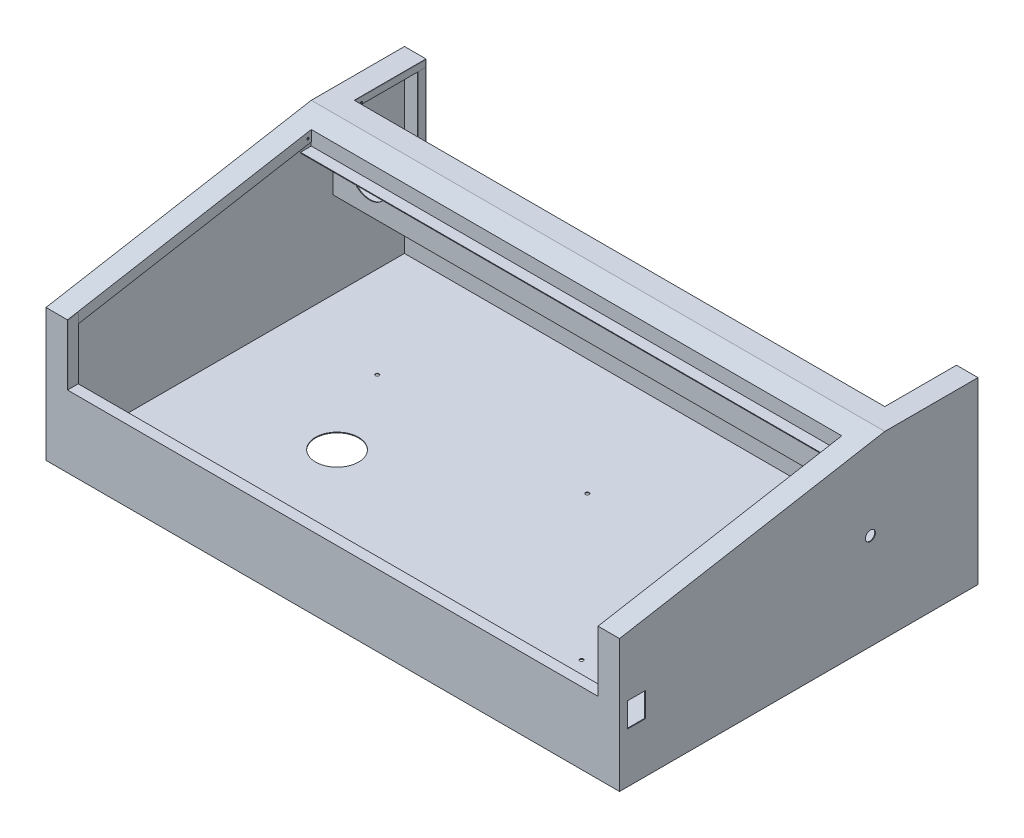
from build123d import *

# Parameters (mm, degrees)
CROQUIS1_W               = 800
CROQUIS1_H               = 500
SALIENTE_EXTRUIR1_DEPTH  = 1
SALIENTE_EXTRUIR2_DEPTH  = 1
SALIENTE_EXTRUIR3_DEPTH  = 1
CROQUIS5_W               = 800
CROQUIS5_H               = 250
SALIENTE_EXTRUIR4_DEPTH  = 1
CROQUIS6_W               = 800
CROQUIS6_H               = 184.759017138
SALIENTE_EXTRUIR5_DEPTH  = 1
SALIENTE_EXTRUIR8_DEPTH  = 800
CROQUIS8_W               = 740
CROQUIS8_H               = 340
CORTAR_EXTRUIR3_DEPTH    = 150
CROQUIS13_W              = 740
CROQUIS13_H              = 15
SALIENTE_EXTRUIR10_DEPTH = 1
SALIENTE_EXTRUIR21_DEPTH = 1
SALIENTE_EXTRUIR23_DEPTH = 1
SALIENTE_EXTRUIR25_DEPTH = 1
SALIENTE_EXTRUIR31_DEPTH = 1
SALIENTE_EXTRUIR32_DEPTH = 1
CROQUIS21_W              = 740
CROQUIS21_H              = 15
SALIENTE_EXTRUIR35_DEPTH = 1
CROQUIS22_W              = 740
CROQUIS22_H              = 100
CORTAR_EXTRUIR4_DEPTH    = 100
CROQUIS23_W              = 798
CROQUIS23_H              = 127
SALIENTE_EXTRUIR36_DEPTH = 1
CROQUIS24_W              = 798
CROQUIS24_H              = 1
SALIENTE_EXTRUIR40_DEPTH = 99
CROQUIS25_W              = 740
CROQUIS25_H              = 1
SALIENTE_EXTRUIR41_DEPTH = 10
CROQUIS26_W              = 99
CROQUIS26_H              = 9
SALIENTE_EXTRUIR43_DEPTH = 1
CROQUIS27_W              = 99
CROQUIS27_H              = 9
SALIENTE_EXTRUIR45_DEPTH = 1
CROQUIS28_W              = 10
CROQUIS28_H              = 90
SALIENTE_EXTRUIR47_DEPTH = 1
CROQUIS29_W              = 740
CROQUIS29_H              = 10
SALIENTE_EXTRUIR48_DEPTH = 1
CROQUIS30_W              = 10
CROQUIS30_H              = 90
SALIENTE_EXTRUIR49_DEPTH = 1
CROQUIS31_R              = 6
CROQUIS31_W              = 180
CROQUIS31_H              = 50
CROQUIS31_W_2            = 35
CROQUIS31_H_2            = 37
CORTAR_EXTRUIR5_DEPTH    = 1
CROQUIS35_W              = 25
CROQUIS35_H              = 34
CORTAR_EXTRUIR8_DEPTH    = 1
CROQUIS36_R              = 7
CORTAR_EXTRUIR9_DEPTH    = 1
CROQUIS37_R              = 30
CROQUIS37_R_2            = 2.5
CROQUIS37_R_3            = 8.5
CORTAR_EXTRUIR11_DEPTH   = 1
CROQUIS40_R              = 1.5
CORTAR_EXTRUIR12_DEPTH   = 1
CROQUIS41_R              = 1.5
CORTAR_EXTRUIR13_DEPTH   = 1
CROQUIS42_R              = 24.75
CORTAR_EXTRUIR14_DEPTH   = 1


with BuildPart() as part:
    # Croquis1 → Saliente-Extruir1 (new body)
    with BuildSketch(Plane(origin=(0, 0, 0), x_dir=(1, 0, 0), z_dir=(0, 1, 0))):
        Rectangle(CROQUIS1_W, CROQUIS1_H)
    extrude(amount=SALIENTE_EXTRUIR1_DEPTH)

    # Croquis3 → Saliente-Extruir2 (add)
    with BuildSketch(Plane(origin=(400, 0, 0), x_dir=(0, 0, -1), z_dir=(1, 0, 0))):
        Polygon((-250, 0), (250, 0), (250, 250), (120, 250), (-250, 184.759017138), align=None)
    extrude(amount=-SALIENTE_EXTRUIR2_DEPTH)

    # Croquis4 → Saliente-Extruir3 (add)
    with BuildSketch(Plane.ZY.offset(400)):
        Polygon((-250, 250), (-250, 1), (250, 1), (250, 184.759017138), (-120, 250), align=None)
    extrude(amount=-SALIENTE_EXTRUIR3_DEPTH)

    # Croquis5 → Saliente-Extruir4 (add)
    with BuildSketch(Plane(origin=(0, 0, -250), x_dir=(-1, 0, 0), z_dir=(0, 0, -1))):
        with Locations((0, 125)):
            Rectangle(CROQUIS5_W, CROQUIS5_H)
    extrude(amount=-SALIENTE_EXTRUIR4_DEPTH)

    # Croquis6 → Saliente-Extruir5 (add)
    with BuildSketch(Plane.XY.offset(250)):
        with Locations((0, 92.379508569)):
            Rectangle(CROQUIS6_W, CROQUIS6_H)
    extrude(amount=-SALIENTE_EXTRUIR5_DEPTH)

    # Croquis7 → Saliente-Extruir8 (add)
    with BuildSketch(Plane(origin=(400, 0, 0), x_dir=(0, 0, -1), z_dir=(1, 0, 0))):
        Polygon((250, 250), (250, 249), (120, 249), (-250, 183.759017138), (-250, 184.759017138), (120, 250), align=None)
    extrude(amount=-SALIENTE_EXTRUIR8_DEPTH)

    # Croquis8 → Cortar-Extruir3 (cut)
    with BuildSketch(Plane(origin=(0, 250, -272.39856565), x_dir=(1, 0, 0), z_dir=(0, -1, 0))):
        with Locations((0, 352.39856565)):
            Rectangle(CROQUIS8_W, CROQUIS8_H)
    extrude(amount=CORTAR_EXTRUIR3_DEPTH, mode=Mode.SUBTRACT)

    # Croquis13 → Saliente-Extruir10 (add)
    with BuildSketch(Plane(origin=(0, 100, 0), x_dir=(1, 0, 0), z_dir=(0, 1, 0))):
        with Locations((0, -242.5)):
            Rectangle(CROQUIS13_W, CROQUIS13_H)
    extrude(amount=-SALIENTE_EXTRUIR10_DEPTH)

    # Croquis16 → Saliente-Extruir25 (add)
    with BuildSketch(Plane.ZY.offset(-370)):
        Polygon((-90, 244.710190579), (-92.644904711, 229.710190579), (235, 171.937553787), (235, 187.403921848), align=None)
    extrude(amount=-SALIENTE_EXTRUIR25_DEPTH)

    # Croquis18 → Saliente-Extruir31 (add)
    with BuildSketch(Plane.XY.offset(-90)):
        Polygon((370, 244.710190579), (370, 224.710190579), (-370.133807939, 224.710190579), (-370, 244.710190579), align=None)
    extrude(amount=-SALIENTE_EXTRUIR31_DEPTH)

    # Croquis19 → Saliente-Extruir32 (add)
    with BuildSketch(Plane(origin=(-370, 0, 0), x_dir=(0, 0, -1), z_dir=(1, 0, 0))):
        Polygon((90, 244.710190579), (90, 229.710190579), (-235, 172.403921848), (-235, 187.403921848), align=None)
    extrude(amount=-SALIENTE_EXTRUIR32_DEPTH)

    # Croquis22 → Cortar-Extruir4 (cut)
    with BuildSketch(Plane(origin=(0, 250, 0), x_dir=(1, 0, 0), z_dir=(0, 1, 0))):
        with Locations((0, 200)):
            Rectangle(CROQUIS22_W, CROQUIS22_H)
    extrude(amount=-CORTAR_EXTRUIR4_DEPTH, mode=Mode.SUBTRACT)

    # Croquis23 → Saliente-Extruir36 (add)
    with BuildSketch(Plane(origin=(0, 0, -150), x_dir=(-1, 0, 0), z_dir=(0, 0, -1))):
        with Locations((0, 185.5)):
            Rectangle(CROQUIS23_W, CROQUIS23_H)
    extrude(amount=-SALIENTE_EXTRUIR36_DEPTH)

    # Croquis25 → Saliente-Extruir41 (add)
    with BuildSketch(Plane(origin=(0, 0, -150), x_dir=(-1, 0, 0), z_dir=(0, 0, -1))):
        with Locations((0, 239.5)):
            Rectangle(CROQUIS25_W, CROQUIS25_H)
    extrude(amount=SALIENTE_EXTRUIR41_DEPTH)

    # Croquis31 → Cortar-Extruir5 (cut)
    with BuildSketch(Plane(origin=(0, 0, -250), x_dir=(-1, 0, 0), z_dir=(0, 0, -1))):
        with Locations((-79, 91)):
            Circle(CROQUIS31_R)
        with Locations((-90, 30)):
            Circle(CROQUIS31_R)
        with Locations((-30, 30)):
            Circle(CROQUIS31_R)
        with Locations((300, 85)):
            Circle(CROQUIS31_R)
        with Locations((140, 70)):
            Rectangle(CROQUIS31_W, CROQUIS31_H)
        Polygon((-350, 52), (-338, 52), (-328, 42), (-328, 20), (-360, 20), (-360, 42), align=None)
        with Locations((-292.5, 51.5)):
            Rectangle(CROQUIS31_W_2, CROQUIS31_H_2)
        with Locations((-233.5, 51.5)):
            Rectangle(CROQUIS31_W_2, CROQUIS31_H_2)
    extrude(amount=-CORTAR_EXTRUIR5_DEPTH, mode=Mode.SUBTRACT)

    # Croquis35 → Cortar-Extruir8 (cut)
    with BuildSketch(Plane(origin=(400, 0, 0), x_dir=(0, 0, -1), z_dir=(1, 0, 0))):
        with Locations((-226.5, 87)):
            Rectangle(CROQUIS35_W, CROQUIS35_H)
    extrude(amount=-CORTAR_EXTRUIR8_DEPTH, mode=Mode.SUBTRACT)

    # Croquis36 → Cortar-Extruir9 (cut)
    with BuildSketch(Plane(origin=(400, 0, 0), x_dir=(0, 0, -1), z_dir=(1, 0, 0))):
        with Locations((100, 134)):
            Circle(CROQUIS36_R)
    extrude(amount=-CORTAR_EXTRUIR9_DEPTH, mode=Mode.SUBTRACT)

    # Croquis37 → Cortar-Extruir11 (cut)
    with BuildSketch(Plane(origin=(0, 1, 0), x_dir=(1, 0, 0), z_dir=(0, 1, 0))):
        with Locations((-209, -35)):
            Circle(CROQUIS37_R)
        with Locations((261, 3)):
            Circle(CROQUIS37_R)
        with Locations((325.5, -118.5)):
            Circle(CROQUIS37_R_2)
        with Locations((325.5, 39.5)):
            Circle(CROQUIS37_R_2)
        with Locations((215.5, 39.5)):
            Circle(CROQUIS37_R_2)
        with Locations((215.5, -118.5)):
            Circle(CROQUIS37_R_2)
        with Locations((18.5, -164.5)):
            Circle(CROQUIS37_R_2)
        with Locations((-106.5, -164.5)):
            Circle(CROQUIS37_R_2)
        with Locations((-271.5, -164.5)):
            Circle(CROQUIS37_R_2)
        with Locations((18.5, 86.5)):
            Circle(CROQUIS37_R_2)
        with Locations((-271.5, 83.5)):
            Circle(CROQUIS37_R_2)
        with Locations((195, -214)):
            Circle(CROQUIS37_R_3)
        with Locations((320, -214)):
            Circle(CROQUIS37_R_3)
    extrude(amount=-CORTAR_EXTRUIR11_DEPTH, mode=Mode.SUBTRACT)

    # Croquis40 → Cortar-Extruir12 (cut)
    with BuildSketch(Plane(origin=(-370, 0, 0), x_dir=(0, 0, -1), z_dir=(1, 0, 0))):
        with Locations((85.485215631, 235.790699387)):
            Circle(CROQUIS40_R)
    extrude(amount=-CORTAR_EXTRUIR12_DEPTH, mode=Mode.SUBTRACT)

    # Croquis42 → Cortar-Extruir14 (cut)
    with BuildSketch(Plane.XY.offset(-149)):
        with Locations((-347.85, 165.95)):
            Circle(CROQUIS42_R)
    extrude(amount=-CORTAR_EXTRUIR14_DEPTH, mode=Mode.SUBTRACT)


with BuildPart() as body_2:
    # Croquis14 → Saliente-Extruir21 (new body)
    with BuildSketch(Plane.ZY.offset(-370)):
        Polygon((235, 100), (249, 100), (249, 183.935344119), (235, 186.403921848), align=None)
    extrude(amount=-SALIENTE_EXTRUIR21_DEPTH)


with BuildPart() as body_3:
    # Croquis15 → Saliente-Extruir23 (new body)
    with BuildSketch(Plane(origin=(-370, 0, 0), x_dir=(0, 0, -1), z_dir=(1, 0, 0))):
        Polygon((-249, 100), (-235, 100), (-235, 186.403921848), (-249, 183.935344119), align=None)
    extrude(amount=-SALIENTE_EXTRUIR23_DEPTH)


with BuildPart() as body_4:
    # Croquis21 → Saliente-Extruir35 (new body)
    with BuildSketch(Plane.XZ.offset(-224.710190579)):
        with Locations((0, -82.5)):
            Rectangle(CROQUIS21_W, CROQUIS21_H)
    extrude(amount=SALIENTE_EXTRUIR35_DEPTH)


with BuildPart() as body_5:
    # Croquis24 → Saliente-Extruir40 (new body)
    with BuildSketch(Plane(origin=(0, 0, -150), x_dir=(-1, 0, 0), z_dir=(0, 0, -1))):
        with Locations((0, 121.5)):
            Rectangle(CROQUIS24_W, CROQUIS24_H)
    extrude(amount=SALIENTE_EXTRUIR40_DEPTH)


with BuildPart() as body_6:
    # Croquis26 → Saliente-Extruir43 (new body)
    with BuildSketch(Plane(origin=(-370, 0, 0), x_dir=(0, 0, -1), z_dir=(1, 0, 0))):
        with Locations((199.5, 244.5)):
            Rectangle(CROQUIS26_W, CROQUIS26_H)
    extrude(amount=-SALIENTE_EXTRUIR43_DEPTH)

    # Croquis41 → Cortar-Extruir13 (cut)
    with BuildSketch(Plane(origin=(-370, 0, 0), x_dir=(0, 0, -1), z_dir=(1, 0, 0))):
        with Locations((160, 242)):
            Circle(CROQUIS41_R)
    extrude(amount=-CORTAR_EXTRUIR13_DEPTH, mode=Mode.SUBTRACT)


with BuildPart() as body_7:
    # Croquis27 → Saliente-Extruir45 (new body)
    with BuildSketch(Plane.ZY.offset(-370)):
        with Locations((-199.5, 244.5)):
            Rectangle(CROQUIS27_W, CROQUIS27_H)
    extrude(amount=-SALIENTE_EXTRUIR45_DEPTH)


with BuildPart() as body_8:
    # Croquis28 → Saliente-Extruir47 (new body)
    with BuildSketch(Plane(origin=(-370, 0, 0), x_dir=(0, 0, -1), z_dir=(1, 0, 0))):
        with Locations((244, 195)):
            Rectangle(CROQUIS28_W, CROQUIS28_H)
    extrude(amount=-SALIENTE_EXTRUIR47_DEPTH)


with BuildPart() as body_9:
    # Croquis29 → Saliente-Extruir48 (new body)
    with BuildSketch(Plane(origin=(0, 150, 0), x_dir=(1, 0, 0), z_dir=(0, 1, 0))):
        with Locations((0, 244)):
            Rectangle(CROQUIS29_W, CROQUIS29_H)
    extrude(amount=-SALIENTE_EXTRUIR48_DEPTH)


with BuildPart() as body_10:
    # Croquis30 → Saliente-Extruir49 (new body)
    with BuildSketch(Plane.ZY.offset(-370)):
        with Locations((-244, 195)):
            Rectangle(CROQUIS30_W, CROQUIS30_H)
    extrude(amount=-SALIENTE_EXTRUIR49_DEPTH)


solid = Compound([part.part, body_2.part, body_3.part, body_4.part, body_5.part, body_6.part, body_7.part, body_8.part, body_9.part, body_10.part])
